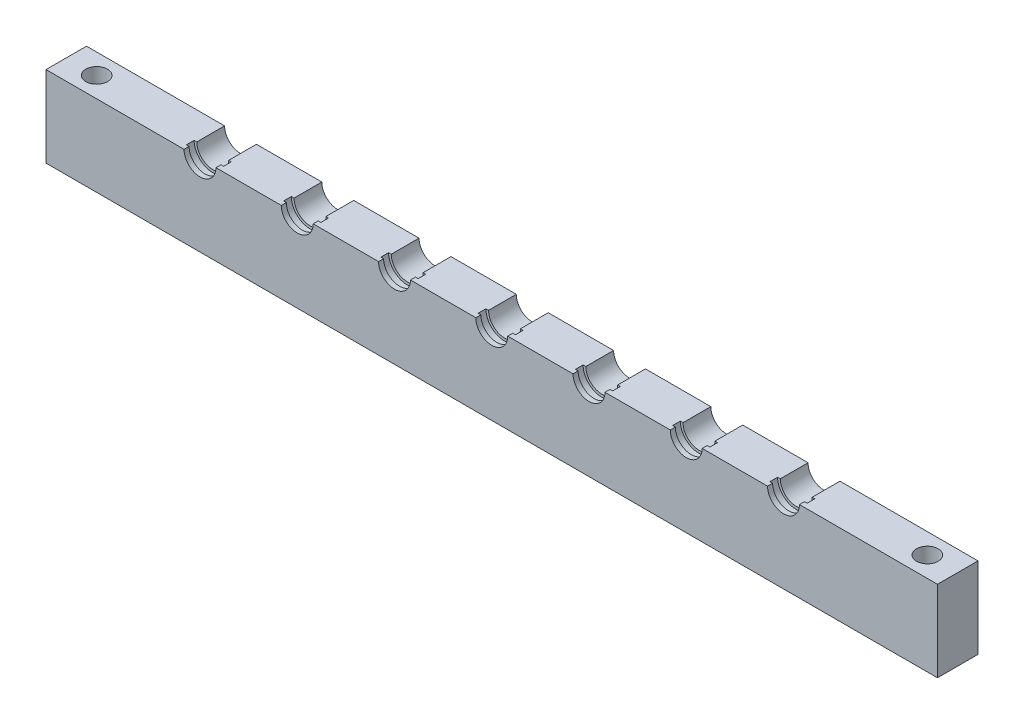
from build123d import *

# Parameters (mm, degrees)
SKETCH1_W            = 139.7
SKETCH1_H            = 12.7
BOSS_EXTRUDE1_DEPTH  = 6.35
M3_CLEARANCE_HOLE1_D = 3.4
LPATTERN1_COUNT      = 4
LPATTERN1_PITCH      = 15.24
LPATTERN2_COUNT      = 4
LPATTERN2_PITCH      = 15.24


with BuildPart() as part:
    # Sketch1 → Boss-Extrude1 (new body)
    with BuildSketch(Plane.XY):
        Rectangle(SKETCH1_W, SKETCH1_H)
    extrude(amount=BOSS_EXTRUDE1_DEPTH)

    # M3 Clearance Hole1 (through all)
    with Locations(Plane(origin=(0, -6.35, 0), x_dir=(-1, 0, 0), z_dir=(0, -1, 0))):
        with Locations((65.0875, -3.175)):
            m3_clearance_hole1 = Hole(M3_CLEARANCE_HOLE1_D / 2)

    # Mirror1: M3 Clearance Hole1 across plane
    add(m3_clearance_hole1.mirror(Plane(origin=(0, 0, 0), x_dir=(0, 0, 1), z_dir=(1, 0, 0))), mode=Mode.SUBTRACT)

    # Sketch9 → Cut-Revolve1 (revolve, cut)
    with BuildSketch(Plane(origin=(0, 6.35, 0), x_dir=(1, 0, 0), z_dir=(0, 1, 0))):
        Polygon((2.5, -5.55625), (2.921, -5.55625), (2.921, -4.34975), (2.5, -4.34975), (2.5, 0), (0, 0), (0, -6.35), (2.5, -6.35), align=None)
    cut_revolve1 = revolve(axis=Axis((0, 6.35, 0), (0, 0, 1)), mode=Mode.SUBTRACT)

    # LPattern1: Cut-Revolve1 ×4
    with Locations(*[(-i * LPATTERN1_PITCH, 0, 0) for i in range(1, LPATTERN1_COUNT)]):
        add(cut_revolve1, mode=Mode.SUBTRACT)

    # LPattern2: Cut-Revolve1 ×4
    with Locations(*[(i * LPATTERN2_PITCH, 0, 0) for i in range(1, LPATTERN2_COUNT)]):
        add(cut_revolve1, mode=Mode.SUBTRACT)


solid = part.part
